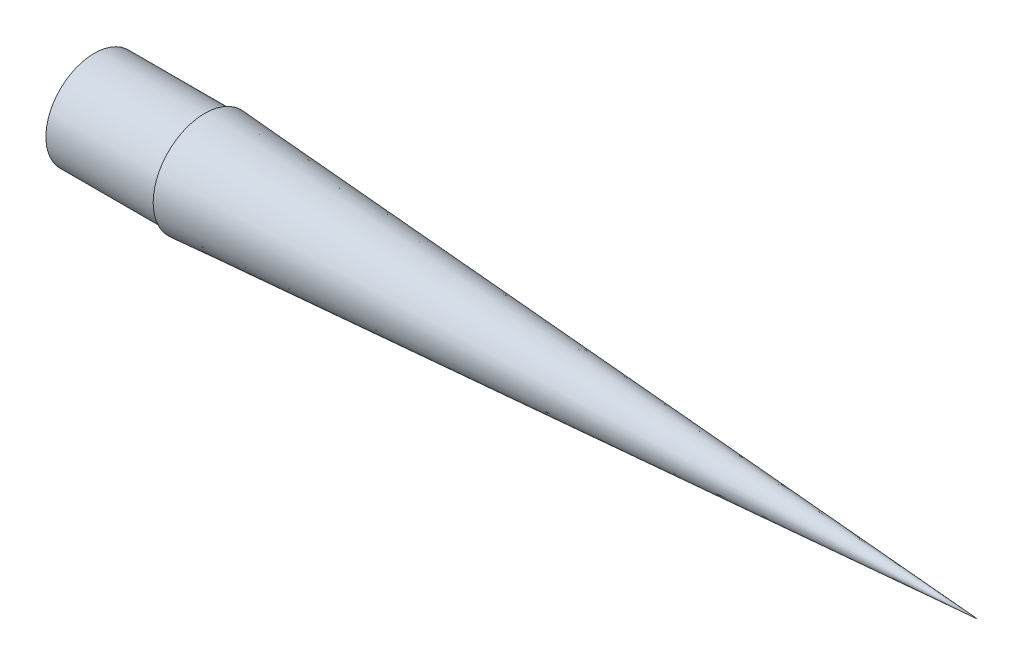
from build123d import *


with BuildPart() as part:
    # Sketch1 → Revolve3 (revolve)
    with BuildSketch(Plane(origin=(0, 0, 0), x_dir=(1, 0, 0), z_dir=(0, 1, 0))):
        Polygon((0, 22.225), (50.8, 22.225), (50.8, 23.6982), (406.4, 0), (387.300922666, 0), (52.07, 22.340746489), (52.07, 20.955), (0, 20.955), align=None)
    revolve(axis=Axis((406.4, 0, 0), (-1, 0, 0)))


solid = part.part
